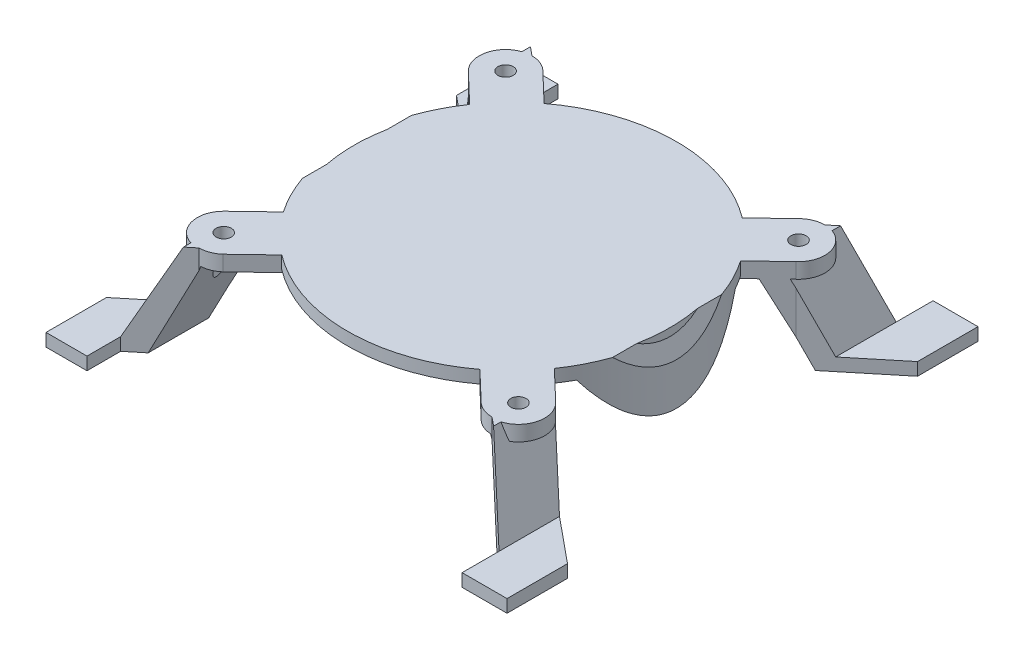
from build123d import *

# Parameters (mm, degrees)
BOSS_EXTRUDE1_DEPTH = 92.4
BOSS_EXTRUDE2_DEPTH = 3
SKETCH3_R           = 1.5
CUT_EXTRUDE1_DEPTH  = 19.319620864
CUT_EXTRUDE2_DEPTH  = 19.319620864


with BuildPart() as part:
    # Sketch1 → Boss-Extrude1 (new body)
    with BuildSketch(Plane.XY):
        Polygon((-52.775, -9.159810432), (-41.775, -9.159810432), (-35.789647492, 6.659810432), (20.684055398, 6.659810432), (26.669407906, -9.159810432), (37.669407906, -9.159810432), (37.669407906, -6.659810432), (28.857556463, -6.659810432), (22.872203955, 9.159810432), (-37.977796049, 9.159810432), (-44.73566716, -6.659810432), (-52.775, -6.659810432), align=None)
    extrude(amount=BOSS_EXTRUDE1_DEPTH)

    # Sketch2 → Boss-Extrude2 (add)
    with BuildSketch(Plane(origin=(0, 9.159810432, 0), x_dir=(1, 0, 0), z_dir=(0, 1, 0))):
        with BuildLine():
            Line((-32.891525537, -77.579025356), (-26.07351169, -71.059265718))
            ThreePointArc((-26.07351169, -71.059265718), (-7.552796047, -77.2), (10.967919597, -71.059265718))
            Line((10.967919597, -71.059265718), (17.785933443, -77.579025356))
            ThreePointArc((17.785933443, -77.579025356), (25.090877354, -77.415674983), (24.927526982, -70.110731072))
            Line((24.927526982, -70.110731072), (18.109513135, -63.590971435))
            ThreePointArc((18.109513135, -63.590971435), (23.447203953, -46.2), (18.109513135, -28.809028565))
            Line((18.109513135, -28.809028565), (24.571212266, -22.629996647))
            ThreePointArc((24.571212266, -22.629996647), (25.083083856, -15.332846234), (17.785933443, -14.820974644))
            Line((17.785933443, -14.820974644), (10.967919597, -21.340734282))
            ThreePointArc((10.967919597, -21.340734282), (-7.552796047, -15.2), (-26.07351169, -21.340734282))
            Line((-26.07351169, -21.340734282), (-32.891525537, -14.820974644))
            ThreePointArc((-32.891525537, -14.820974644), (-40.188675949, -15.332846234), (-39.676804359, -22.629996647))
            Line((-39.676804359, -22.629996647), (-33.215105229, -28.809028565))
            ThreePointArc((-33.215105229, -28.809028565), (-38.552796047, -46.2), (-33.215105229, -63.590971435))
            Line((-33.215105229, -63.590971435), (-40.033119075, -70.110731072))
            ThreePointArc((-40.033119075, -70.110731072), (-40.196469448, -77.415674983), (-32.891525537, -77.579025356))
        make_face()
    extrude(amount=-BOSS_EXTRUDE2_DEPTH)

    # Sketch3 → Cut-Extrude1 (cut, through all)
    with BuildSketch(Plane(origin=(0, 9.159810432, 0), x_dir=(1, 0, 0), z_dir=(0, 1, 0))):
        with Locations((-36.284164948, -18.725485646)):
            Circle(SKETCH3_R)
        with Locations((21.178572854, -18.725485646)):
            Circle(SKETCH3_R)
        with Locations((-36.462322306, -73.844878214)):
            Circle(SKETCH3_R)
        with Locations((21.356730213, -73.844878214)):
            Circle(SKETCH3_R)
    extrude(amount=-CUT_EXTRUDE1_DEPTH, mode=Mode.SUBTRACT)

    # Sketch4 → Cut-Extrude2 (cut, through all)
    with BuildSketch(Plane(origin=(0, 9.159810432, 0), x_dir=(1, 0, 0), z_dir=(0, 1, 0))):
        with BuildLine():
            Line((-44.73566716, -6.607100908), (-36.284164948, -13.552941945))
            ThreePointArc((-36.284164948, -13.552941945), (-34.473232239, -13.880309585), (-32.891525537, -14.820974644))
            Line((-32.891525537, -14.820974644), (-26.99023083, -20.464117047))
            ThreePointArc((-26.99023083, -20.464117047), (-7.552796047, -13.948650534), (11.884638737, -20.464117047))
            Line((11.884638737, -20.464117047), (17.785933443, -14.820974644))
            ThreePointArc((17.785933443, -14.820974644), (19.367640146, -13.880309585), (21.178572854, -13.552941945))
            Line((21.178572854, -13.552941945), (28.857556463, -7.241992941))
            Line((28.857556463, -7.241992941), (28.857556463, 0))
            Line((28.857556463, 0), (-44.73566716, 0))
            Line((-44.73566716, 0), (-44.73566716, -6.607100908))
        make_face()
        with BuildLine():
            Line((28.857556463, -85.158007059), (21.178572854, -78.847058055))
            ThreePointArc((21.178572854, -78.847058055), (19.367640146, -78.519690415), (17.785933443, -77.579025356))
            Line((17.785933443, -77.579025356), (11.884638737, -71.935882953))
            ThreePointArc((11.884638737, -71.935882953), (-7.552796047, -78.451349466), (-26.99023083, -71.935882953))
            Line((-26.99023083, -71.935882953), (-32.891525537, -77.579025356))
            ThreePointArc((-32.891525537, -77.579025356), (-34.473232239, -78.519690415), (-36.284164948, -78.847058055))
            Line((-36.284164948, -78.847058055), (-44.73566716, -85.792899092))
            Line((-44.73566716, -85.792899092), (-44.73566716, -92.4))
            Line((-44.73566716, -92.4), (28.857556463, -92.4))
            Line((28.857556463, -92.4), (28.857556463, -85.158007059))
        make_face()
        with BuildLine():
            Line((-39.676804359, -22.629996647), (-52.775, -11.865284942))
            Line((-52.775, -11.865284942), (-52.775, -80.534715058))
            Line((-52.775, -80.534715058), (-39.676804359, -69.770003353))
            Line((-39.676804359, -69.770003353), (-34.131824369, -64.46758867))
            ThreePointArc((-34.131824369, -64.46758867), (-39.804145512, -46.2), (-34.131824369, -27.93241133))
            Line((-34.131824369, -27.93241133), (-39.676804359, -22.629996647))
        make_face()
        with BuildLine():
            Line((24.571212266, -69.770003353), (37.669407906, -80.534715058))
            Line((37.669407906, -80.534715058), (37.669407906, -11.865284942))
            Line((37.669407906, -11.865284942), (24.571212266, -22.629996647))
            Line((24.571212266, -22.629996647), (19.026232275, -27.93241133))
            ThreePointArc((19.026232275, -27.93241133), (24.698553419, -46.2), (19.026232275, -64.46758867))
            Line((19.026232275, -64.46758867), (24.571212266, -69.770003353))
        make_face()
    extrude(amount=-CUT_EXTRUDE2_DEPTH, mode=Mode.SUBTRACT)


solid = part.part
